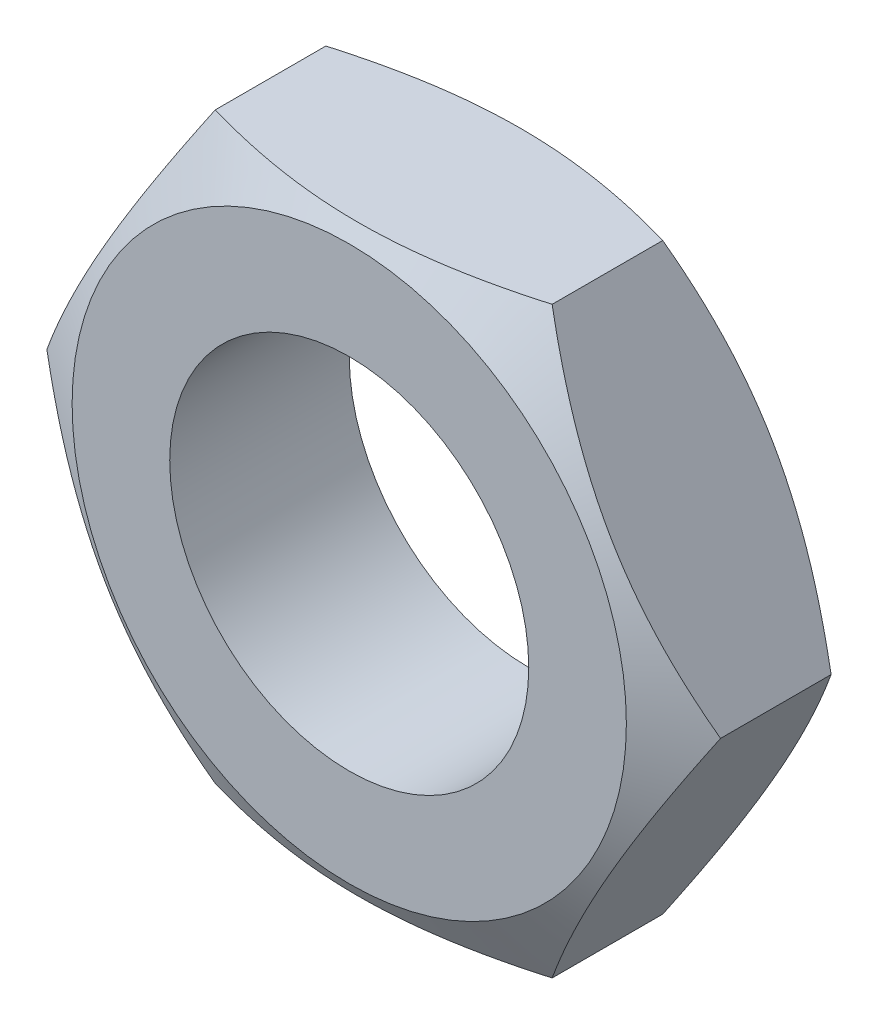
from build123d import *

# Parameters (mm, degrees)
BASENUTSKE_R       = 4
BASENUT_DEPTH      = 4
SKETCH6_OUTSIDE_W  = 38.384
SKETCH6_OUTSIDE_H  = 36.372
SKETCH6_OUTSIDE_R  = 6.175
CUT_EXTRUDE2_DEPTH = 5
CUT_EXTRUDE2_TAPER = 60


with BuildPart() as part:
    # BaseNutSke → BaseNut (new body)
    with BuildSketch(Plane.XY):
        Polygon((3.75277675, -6.5), (-3.75277675, -6.5), (-7.505553499, 0), (-3.75277675, 6.5), (3.75277675, 6.5), (7.505553499, 0), align=None)
        Circle(BASENUTSKE_R, mode=Mode.SUBTRACT)
    extrude(amount=-BASENUT_DEPTH)

    # Sketch6 outside → Cut-Extrude2 (cut, through all)
    with BuildSketch(Plane(origin=(0, 0, -4), x_dir=(-1, 0, 0), z_dir=(0, 0, -1))):
        Rectangle(SKETCH6_OUTSIDE_W, SKETCH6_OUTSIDE_H)
        Circle(SKETCH6_OUTSIDE_R, mode=Mode.SUBTRACT)
    cut_extrude2 = extrude(amount=-CUT_EXTRUDE2_DEPTH, taper=CUT_EXTRUDE2_TAPER, mode=Mode.SUBTRACT)

    # Mirror1: Cut-Extrude2 across plane
    add(cut_extrude2.mirror(Plane(origin=(0, 0, -2), x_dir=(1, 0, 0), z_dir=(0, 0, -1))), mode=Mode.SUBTRACT)


solid = part.part
